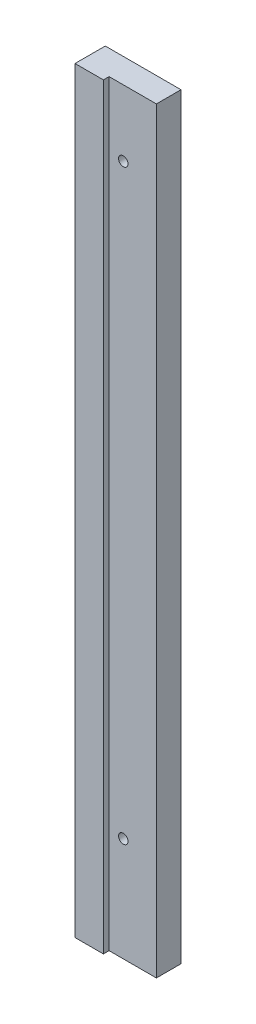
from build123d import *

# Parameters (mm, degrees)
SKETCH1_W         = 40
SKETCH1_H         = 400
EXTRUDE1_DEPTH    = 16
EXTRUDE2_REACH    = 402
SKETCH2_W         = 25
SKETCH2_H         = 3
M6_TAPPED_HOLE1_D = 5


with BuildPart() as part:
    # Sketch1 → Extrude1 (new body)
    with BuildSketch(Plane.XY):
        Rectangle(SKETCH1_W, SKETCH1_H)
    extrude(amount=EXTRUDE1_DEPTH)

    # Sketch2 → Extrude2 (cut, up to next)
    with BuildSketch(Plane.XZ.offset(200), mode=Mode.PRIVATE) as extrude2_sk1:
        with Locations((7.5, 14.5)):
            Rectangle(SKETCH2_W, SKETCH2_H)
    extrude2_tool1 = extrude(extrude2_sk1.sketch, amount=-EXTRUDE2_REACH, mode=Mode.PRIVATE) & part.part
    add(extrude2_tool1.solids().sort_by_distance((7.5, -200, 14.5))[0], mode=Mode.SUBTRACT)

    # M6 Tapped Hole1 (through all)
    with Locations(Plane(origin=(0, 0, 0), x_dir=(-1, 0, 0), z_dir=(0, 0, -1))):
        with Locations((-2.5, 165), (-2.5, -145)):
            Hole(M6_TAPPED_HOLE1_D / 2)


solid = part.part
